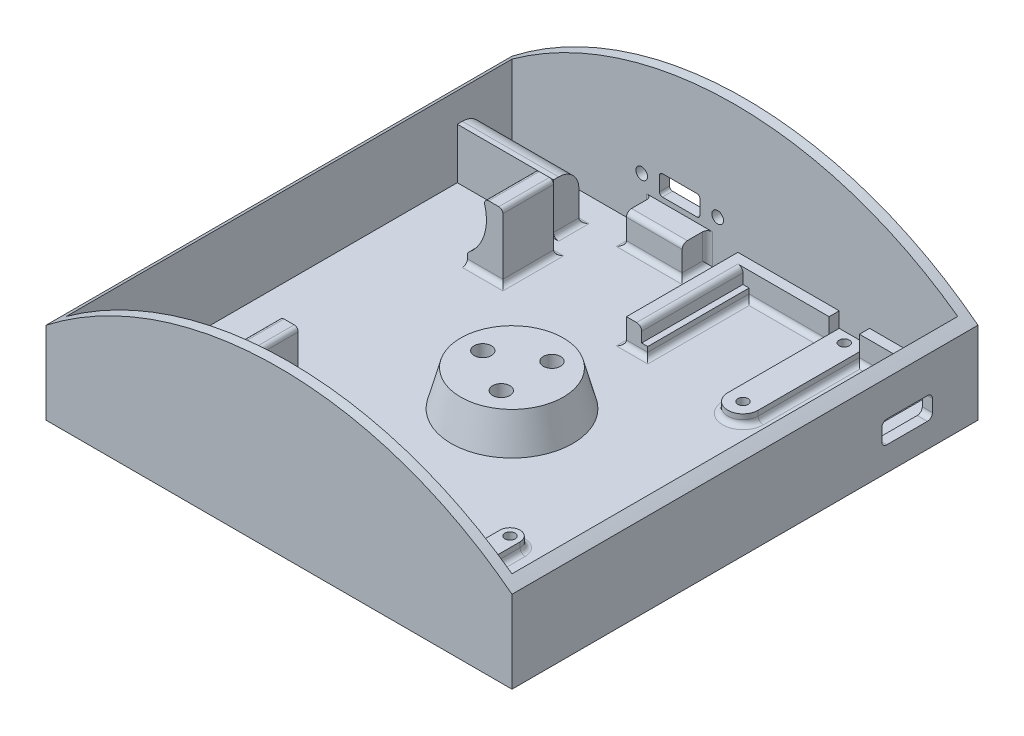
from build123d import *

# Parameters (mm, degrees)
SKETCH1_W               = 92
SKETCH1_H               = 92
BOSS_EXTRUDE1_DEPTH     = 2
SKETCH7_R               = 12
BOSS_EXTRUDE2_DEPTH     = 7
BOSS_EXTRUDE2_TAPER     = 15
SKETCH4_R               = 1.7
CUT_EXTRUDE3_DEPTH      = 8.0000001
CUT_EXTRUDE3_DEPTH_BACK = 3
CUT_EXTRUDE4_START      = -0.4
SKETCH6_R               = 3.5
CUT_EXTRUDE4_DEPTH      = 2.6
SKETCH8_W               = 19
SKETCH8_H               = 5
BOSS_EXTRUDE3_DEPTH     = 10
FILLET1_R               = 4
SKETCH12_W              = 7
SKETCH12_H              = 10
BOSS_EXTRUDE6_DEPTH     = 13
SKETCH16_R              = 9.25
CUT_EXTRUDE5_DEPTH      = 60.4
FILLET3_R               = 0.8
SKETCH17_W              = 92
SKETCH17_H              = 92
SKETCH17_W_2            = 88
SKETCH17_H_2            = 88
BOSS_EXTRUDE11_DEPTH    = 30
SKETCH19_R              = 105
SKETCH19_R_2            = 75
CUT_EXTRUDE6_DEPTH      = 92
SKETCH20_W              = 17.4
SKETCH20_H              = 2
BOSS_EXTRUDE12_DEPTH    = 5
SKETCH21_W              = 3
SKETCH21_H              = 20
SKETCH21_W_2            = 1.2
BOSS_EXTRUDE13_DEPTH    = 2
SKETCH22_R              = 1
CUT_EXTRUDE7_DEPTH      = 5
CUT_EXTRUDE8_DEPTH      = 3
BOSS_EXTRUDE14_DEPTH    = 2
SKETCH25_R              = 1
CUT_EXTRUDE9_DEPTH      = 5
SKETCH27_W              = 11
SKETCH27_H              = 5
BOSS_EXTRUDE15_DEPTH    = 6
SKETCH28_R              = 1.15
CUT_EXTRUDE10_DEPTH     = 3
FILLET4_R               = 1
FILLET5_R               = 1
FILLET6_R               = 1


with BuildPart() as part:
    # Sketch1 → Boss-Extrude1 (new body)
    with BuildSketch(Plane(origin=(0, 0, 0), x_dir=(1, 0, 0), z_dir=(0, 1, 0))):
        Rectangle(SKETCH1_W, SKETCH1_H)
    extrude(amount=BOSS_EXTRUDE1_DEPTH)

    # Sketch7 → Boss-Extrude2 (add)
    with BuildSketch(Plane(origin=(0, 2, 0), x_dir=(1, 0, 0), z_dir=(0, 1, 0))):
        Circle(SKETCH7_R)
    extrude(amount=BOSS_EXTRUDE2_DEPTH, taper=BOSS_EXTRUDE2_TAPER)

    # Sketch4 → Cut-Extrude3 (cut, two sides)
    with BuildSketch(Plane(origin=(0, 2, 0), x_dir=(1, 0, 0), z_dir=(0, 1, 0))) as cut_extrude3_sk:
        with Locations((-5.77, 0)):
            Circle(SKETCH4_R)
        with Locations((2.885, 4.99696658)):
            Circle(SKETCH4_R)
        with Locations((2.885, -4.99696658)):
            Circle(SKETCH4_R)
    extrude(amount=CUT_EXTRUDE3_DEPTH, mode=Mode.SUBTRACT)
    extrude(cut_extrude3_sk.sketch, amount=-CUT_EXTRUDE3_DEPTH_BACK, mode=Mode.SUBTRACT)

    # Sketch6 → Cut-Extrude4 (cut, through all)
    with BuildSketch(Plane(origin=(0, 2, 0), x_dir=(1, 0, 0), z_dir=(0, 1, 0)).offset(CUT_EXTRUDE4_START)):
        with Locations((2.885, 4.99696658)):
            Circle(SKETCH6_R)
        with Locations((-5.77, 0)):
            Circle(SKETCH6_R)
        with Locations((2.885, -4.99696658)):
            Circle(SKETCH6_R)
    extrude(amount=-CUT_EXTRUDE4_DEPTH, mode=Mode.SUBTRACT)

    # Sketch8 → Boss-Extrude3 (add)
    with BuildSketch(Plane(origin=(0, 2, 0), x_dir=(1, 0, 0), z_dir=(0, 1, 0))):
        with Locations((-34.5, -35.7)):
            Rectangle(SKETCH8_W, SKETCH8_H)
        with Locations((-34.5, 35.7)):
            Rectangle(SKETCH8_W, SKETCH8_H)
    extrude(amount=BOSS_EXTRUDE3_DEPTH)

    # Fillet1
    fillet1_edges = [part.edges().sort_by_distance(p)[0] for p in [
        (-34.5, 12, -38.2),
        (-34.5, 12, 38.2),
    ]]
    fillet(fillet1_edges, radius=FILLET1_R)

    # Sketch12 → Boss-Extrude6 (add)
    with BuildSketch(Plane(origin=(0, 2, 0), x_dir=(1, 0, 0), z_dir=(0, 1, 0))):
        with Locations((-25.5, 25.2)):
            Rectangle(SKETCH12_W, SKETCH12_H)
        with Locations((-25.5, -25.2)):
            Rectangle(SKETCH12_W, SKETCH12_H)
    extrude(amount=BOSS_EXTRUDE6_DEPTH)

    # Sketch16 → Cut-Extrude5 (cut)
    with BuildSketch(Plane.XY.offset(30.2)):
        with Locations((-34.5, 11.5)):
            Circle(SKETCH16_R)
    extrude(amount=-CUT_EXTRUDE5_DEPTH, mode=Mode.SUBTRACT)

    # Fillet3
    fillet3_edges = [part.edges().sort_by_distance(p)[0] for p in [
        (-22, 15, -25.2),
        (-22, 15, 25.2),
        (-25.937728105, 15, -25.2),
        (-29, 4.06276261, 25.2),
        (-25.937728105, 15, 25.2),
        (-29, 4.06276261, -25.2),
    ]]
    fillet(fillet3_edges, radius=FILLET3_R)

    # Sketch17 → Boss-Extrude11 (add)
    with BuildSketch(Plane(origin=(0, 2, 0), x_dir=(1, 0, 0), z_dir=(0, 1, 0))):
        Rectangle(SKETCH17_W, SKETCH17_H)
        Rectangle(SKETCH17_W_2, SKETCH17_H_2, mode=Mode.SUBTRACT)
    extrude(amount=BOSS_EXTRUDE11_DEPTH)

    # Sketch19 → Cut-Extrude6 (cut)
    with BuildSketch(Plane.XY.offset(46)):
        with Locations((0, -43)):
            Circle(SKETCH19_R)
        with Locations((0, -43)):
            Circle(SKETCH19_R_2, mode=Mode.SUBTRACT)
    extrude(amount=-CUT_EXTRUDE6_DEPTH, mode=Mode.SUBTRACT)

    # Sketch20 → Boss-Extrude12 (add)
    with BuildSketch(Plane(origin=(0, 2, 0), x_dir=(1, 0, 0), z_dir=(0, 1, 0))):
        Polygon((0.6, 44), (0.6, 22), (3.6, 22), (3.6, 42), (20.6, 42), (20.6, 44), align=None)
        with Locations((35.3, 43)):
            Rectangle(SKETCH20_W, SKETCH20_H)
    extrude(amount=BOSS_EXTRUDE12_DEPTH)

    # Sketch21 → Boss-Extrude13 (add)
    with BuildSketch(Plane(origin=(0, 2, 0), x_dir=(1, 0, 0), z_dir=(0, 1, 0))):
        with BuildLine():
            Line((26.6, 44), (20.6, 44))
            Line((20.6, 44), (20.6, 22))
            ThreePointArc((20.6, 22), (23.6, 19), (26.6, 22))
            Line((26.6, 22), (26.6, 44))
        make_face()
        with Locations((42.5, 32)):
            Rectangle(SKETCH21_W, SKETCH21_H)
        with Locations((4.2, 32)):
            Rectangle(SKETCH21_W_2, SKETCH21_H)
    extrude(amount=BOSS_EXTRUDE13_DEPTH)

    # Sketch22 → Cut-Extrude7 (cut, through all)
    with BuildSketch(Plane(origin=(0, 4, 0), x_dir=(1, 0, 0), z_dir=(0, 1, 0))):
        with Locations((23.6, 22)):
            Circle(SKETCH22_R)
        with Locations((23.6, 42)):
            Circle(SKETCH22_R)
    extrude(amount=-CUT_EXTRUDE7_DEPTH, mode=Mode.SUBTRACT)

    # Sketch23 → Cut-Extrude8 (cut, through all)
    with BuildSketch(Plane.ZY.offset(-44)):
        with BuildLine():
            Line((-36, 9.2), (-28, 9.2))
            ThreePointArc((-28, 9.2), (-27.292893219, 8.907106781), (-27, 8.2))
            Line((-27, 8.2), (-27, 5.8))
            ThreePointArc((-27, 5.8), (-27.292893219, 5.092893219), (-28, 4.8))
            Line((-28, 4.8), (-36, 4.8))
            ThreePointArc((-36, 4.8), (-36.707106781, 5.092893219), (-37, 5.8))
            Line((-37, 5.8), (-37, 8.2))
            ThreePointArc((-37, 8.2), (-36.707106781, 8.907106781), (-36, 9.2))
        make_face()
    extrude(amount=-CUT_EXTRUDE8_DEPTH, mode=Mode.SUBTRACT)

    # Sketch24 → Boss-Extrude14 (add)
    with BuildSketch(Plane(origin=(0, 2, 0), x_dir=(1, 0, 0), z_dir=(0, 1, 0))):
        with BuildLine():
            Line((21.6, -44), (25.6, -44))
            Line((25.6, -44), (25.6, -24))
            ThreePointArc((25.6, -24), (23.6, -22), (21.6, -24))
            Line((21.6, -24), (21.6, -44))
        make_face()
        with BuildLine():
            Line((1.6, -44), (5.6, -44))
            Line((5.6, -44), (5.6, -24))
            ThreePointArc((5.6, -24), (3.6, -22), (1.6, -24))
            Line((1.6, -24), (1.6, -44))
        make_face()
        with BuildLine():
            Line((44, 6.5), (37, 6.5))
            ThreePointArc((37, 6.5), (33.5, 3), (37, -0.5))
            Line((37, -0.5), (44, -0.5))
            Line((44, -0.5), (44, 6.5))
        make_face()
    extrude(amount=BOSS_EXTRUDE14_DEPTH)

    # Sketch25 → Cut-Extrude9 (cut, through all)
    with BuildSketch(Plane(origin=(0, 4, 0), x_dir=(1, 0, 0), z_dir=(0, 1, 0))):
        with Locations((3.6, -24)):
            Circle(SKETCH25_R)
        with Locations((23.6, -24)):
            Circle(SKETCH25_R)
        with Locations((37, 3)):
            Circle(SKETCH25_R)
    extrude(amount=-CUT_EXTRUDE9_DEPTH, mode=Mode.SUBTRACT)

    # Sketch27 → Boss-Extrude15 (add)
    with BuildSketch(Plane(origin=(0, 2, 0), x_dir=(1, 0, 0), z_dir=(0, 1, 0))):
        with Locations((-10.9, 41.5)):
            Rectangle(SKETCH27_W, SKETCH27_H)
    extrude(amount=BOSS_EXTRUDE15_DEPTH)

    # Sketch28 → Cut-Extrude10 (cut, through all)
    with BuildSketch(Plane.XY.offset(-44)):
        with Locations((-18.4, 11)):
            Circle(SKETCH28_R)
        with Locations((-3.4, 11)):
            Circle(SKETCH28_R)
        with BuildLine():
            Line((-14.3, 13), (-7.5, 13))
            ThreePointArc((-7.5, 13), (-7.075735931, 12.824264069), (-6.9, 12.4))
            Line((-6.9, 12.4), (-6.9, 9.6))
            ThreePointArc((-6.9, 9.6), (-7.075735931, 9.175735931), (-7.5, 9))
            Line((-7.5, 9), (-14.3, 9))
            ThreePointArc((-14.3, 9), (-14.724264069, 9.175735931), (-14.9, 9.6))
            Line((-14.9, 9.6), (-14.9, 12.4))
            ThreePointArc((-14.9, 12.4), (-14.724264069, 12.824264069), (-14.3, 13))
        make_face()
    extrude(amount=-CUT_EXTRUDE10_DEPTH, mode=Mode.SUBTRACT)

    # Fillet4
    fillet4_edges = [part.edges().sort_by_distance(p)[0] for p in [
        (3.6, 7, -32),
    ]]
    fillet(fillet4_edges, radius=FILLET4_R)

    # Fillet5
    fillet5_edges = [part.edges().sort_by_distance(p)[0] for p in [
        (-16.4, 2, -41.5),
        (-16.4, 5, -44),
        (-10.9, 2, -39),
        (-5.4, 2, -41.5),
        (-5.4, 5, -44),
        (-10.9, 8, -39),
    ]]
    fillet(fillet5_edges, radius=FILLET5_R)

    # Fillet6
    fillet6_edges = [part.edges().sort_by_distance(p)[0] for p in [
        (26.6, 2, -32),
        (23.6, 2, -19),
        (12.7, 2, -42),
        (33.8, 2, -42),
        (42.5, 2, -22),
        (41, 2, -32),
        (20.6, 2, -32),
        (4.8, 2, -32),
        (2.7, 2, -22),
        (0.6, 2, -33),
        (40.5, 2, -6.5),
        (33.5, 2, -3),
        (21.6, 2, 34),
        (23.6, 2, 22),
        (1.6, 2, 34),
        (3.6, 2, 22),
        (40.5, 2, 0.5),
        (25.6, 2, 34),
        (5.6, 2, 34),
        (-34.5, 2, 38.2),
        (-25, 2, 35.7),
        (-25.5, 2, 30.2),
        (-25.5, 2, 20.2),
        (-22, 2, 25.2),
        (-34.5, 2, -38.2),
        (-25, 2, -35.7),
        (-25.5, 2, -30.2),
        (-25.5, 2, -20.2),
        (-22, 2, -25.2),
    ]]
    fillet(fillet6_edges, radius=FILLET6_R)


solid = part.part
